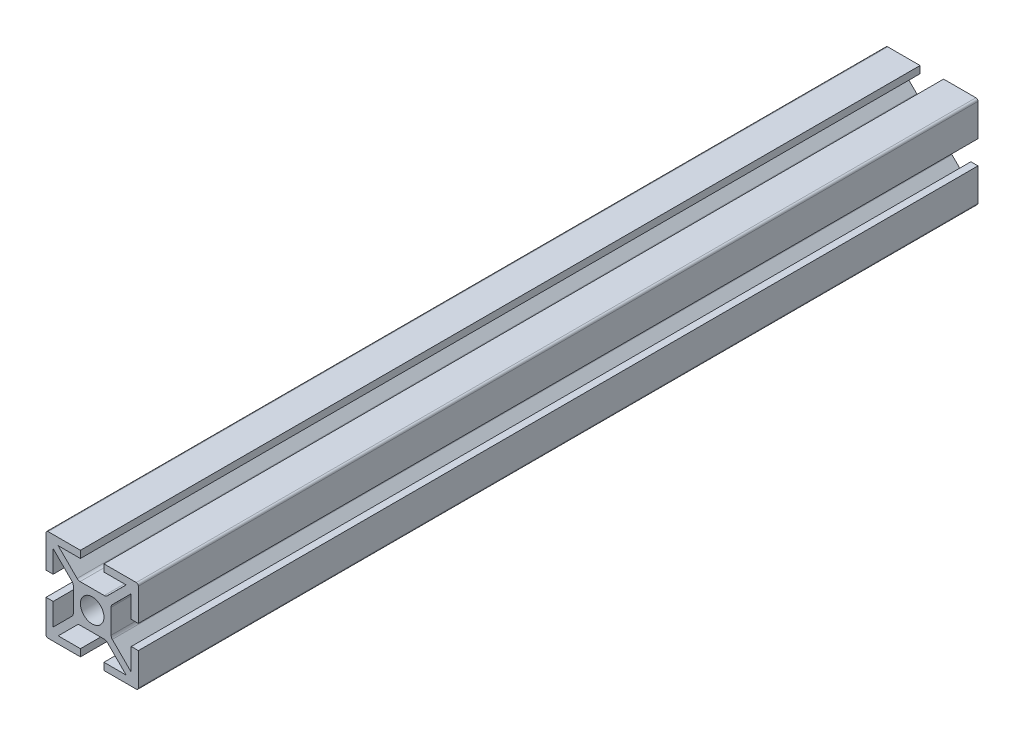
from build123d import *

# Parameters (mm, degrees)
EXTRUSION1_DEPTH        = 200
ESQUISSE2_R             = 2.8
ENL_V_MAT_EXTRU_1_DEPTH = 201
CONG_1_R                = 0.5
CONG_2_R                = 1


with BuildPart() as part:
    # Esquisse1 → Extrusion1 (new body)
    with BuildSketch(Plane.XY):
        Polygon((-2.8, 11), (-2.8, 9.3), (-8.097918472, 9.3), (-3.297918472, 4.5), (3.297918472, 4.5), (8.097918472, 9.3), (2.8, 9.3), (2.8, 11), (11, 11), (11, 2.8), (9.3, 2.8), (9.3, 8.097918472), (4.5, 3.297918472), (4.5, -3.297918472), (9.3, -8.097918472), (9.3, -2.8), (11, -2.8), (11, -11), (2.8, -11), (2.8, -9.3), (8.097918472, -9.3), (3.297918472, -4.5), (-3.297918472, -4.5), (-8.097918472, -9.3), (-2.8, -9.3), (-2.8, -11), (-11, -11), (-11, -2.8), (-9.3, -2.8), (-9.3, -8.097918472), (-4.5, -3.297918472), (-4.5, 3.297918472), (-9.3, 8.097918472), (-9.3, 2.8), (-11, 2.8), (-11, 11), align=None)
    extrude(amount=EXTRUSION1_DEPTH)

    # Esquisse2 → Enlèv. mat.-Extru.1 (cut, through all)
    with BuildSketch(Plane(origin=(0, 0, 0), x_dir=(-1, 0, 0), z_dir=(0, 0, -1))):
        Circle(ESQUISSE2_R)
    extrude(amount=-ENL_V_MAT_EXTRU_1_DEPTH, mode=Mode.SUBTRACT)

    # Congé1
    cong_1_edges = [part.edges().sort_by_distance(p)[0] for p in [
        (-11, 11, 100),
        (11, 11, 100),
        (11, -11, 100),
        (-11, -11, 100),
    ]]
    fillet(cong_1_edges, radius=CONG_1_R)

    # Congé2
    cong_2_edges = [part.edges().sort_by_distance(p)[0] for p in [
        (-4.5, -3.297918472, 100),
        (-4.5, 3.297918472, 100),
        (-3.297918472, 4.5, 100),
        (3.297918472, 4.5, 100),
        (4.5, 3.297918472, 100),
        (4.5, -3.297918472, 100),
        (3.297918472, -4.5, 100),
        (-3.297918472, -4.5, 100),
    ]]
    fillet(cong_2_edges, radius=CONG_2_R)


solid = part.part
